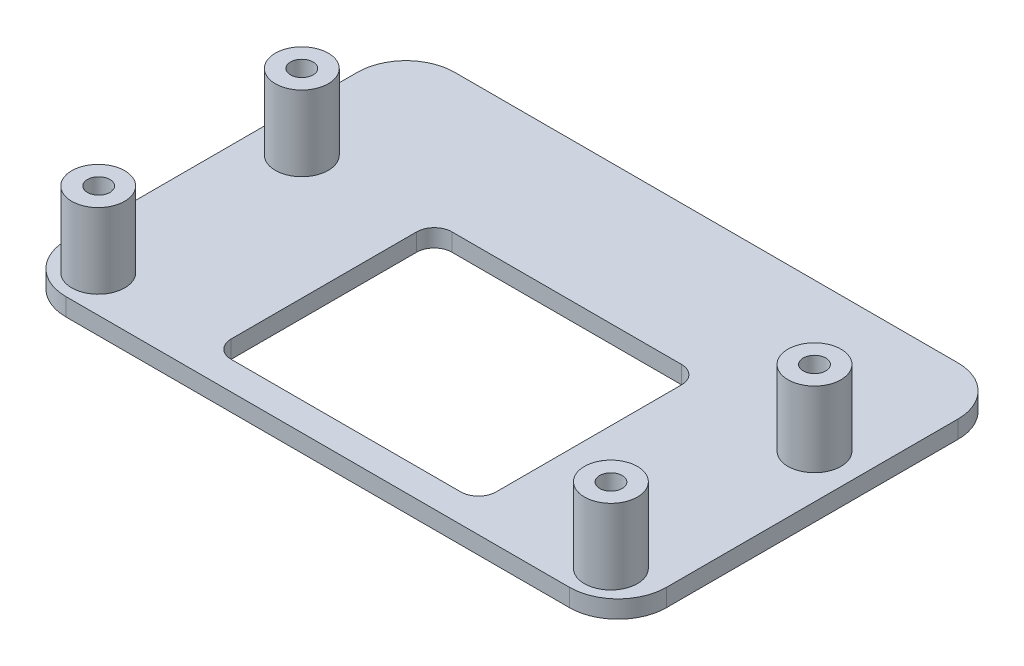
from build123d import *

# Parameters (mm, degrees)
SKETCH_1_W          = 68
SKETCH_1_H          = 44
EXTRUDE_1_DEPTH     = 2
FILLET_1_R          = 5.5
SKETCH_2_W          = 30
SKETCH_2_H          = 25
CUT_EXTRUDE_1_DEPTH = 3
FILLET_2_R          = 2
SKETCH_3_R          = 3
EXTRUDE_2_DEPTH     = 8.5
SKETCH_4_R          = 1.275
CUT_EXTRUDE_2_DEPTH = 6
CUT_EXTRUDE_2_TAPER = 2


with BuildPart() as part:
    # 草图1 → 凸台-拉伸1 (new body)
    with BuildSketch(Plane(origin=(0, 0, 0), x_dir=(1, 0, 0), z_dir=(0, 1, 0))):
        with Locations((-0.499435028, -2.675706215)):
            Rectangle(SKETCH_1_W, SKETCH_1_H)
    extrude(amount=EXTRUDE_1_DEPTH)

    # 圆角1
    fillet_1_edges = [part.edges().sort_by_distance(p)[0] for p in [
        (-34.499435028, 1, -19.324293785),
        (33.500564972, 1, -19.324293785),
        (33.500564972, 1, 24.675706215),
        (-34.499435028, 1, 24.675706215),
    ]]
    fillet(fillet_1_edges, radius=FILLET_1_R)

    # 草图2 → 切除-拉伸1 (cut, through all)
    with BuildSketch(Plane.XZ):
        with Locations((-0.499435028, 8.975706215)):
            Rectangle(SKETCH_2_W, SKETCH_2_H)
    extrude(amount=-CUT_EXTRUDE_1_DEPTH, mode=Mode.SUBTRACT)

    # 圆角2
    fillet_2_edges = [part.edges().sort_by_distance(p)[0] for p in [
        (14.500564972, 1, 21.475706215),
        (14.500564972, 1, -3.524293785),
        (-15.499435028, 1, -3.524293785),
        (-15.499435028, 1, 21.475706215),
    ]]
    fillet(fillet_2_edges, radius=FILLET_2_R)

    # 草图3 → 凸台-拉伸2 (add)
    with BuildSketch(Plane(origin=(0, 2, 0), x_dir=(1, 0, 0), z_dir=(0, 1, 0))):
        with Locations((-29.524435028, 2.549293785)):
            Circle(SKETCH_3_R)
        with Locations((-29.524435028, -20.500706215)):
            Circle(SKETCH_3_R)
        with Locations((28.500564972, -20.475706215)):
            Circle(SKETCH_3_R)
        with Locations((28.525564972, 2.549293785)):
            Circle(SKETCH_3_R)
    extrude(amount=EXTRUDE_2_DEPTH)

    # 草图4 → 切除-拉伸2 (cut)
    with BuildSketch(Plane(origin=(0, 10.5, 0), x_dir=(1, 0, 0), z_dir=(0, 1, 0))):
        with Locations((-29.524435028, 2.549293785)):
            Circle(SKETCH_4_R)
        with Locations((-29.499435028, -20.475706215)):
            Circle(SKETCH_4_R)
        with Locations((28.525564972, -20.500706215)):
            Circle(SKETCH_4_R)
        with Locations((28.525564972, 2.549293785)):
            Circle(SKETCH_4_R)
    extrude(amount=-CUT_EXTRUDE_2_DEPTH, taper=CUT_EXTRUDE_2_TAPER, mode=Mode.SUBTRACT)


solid = part.part
